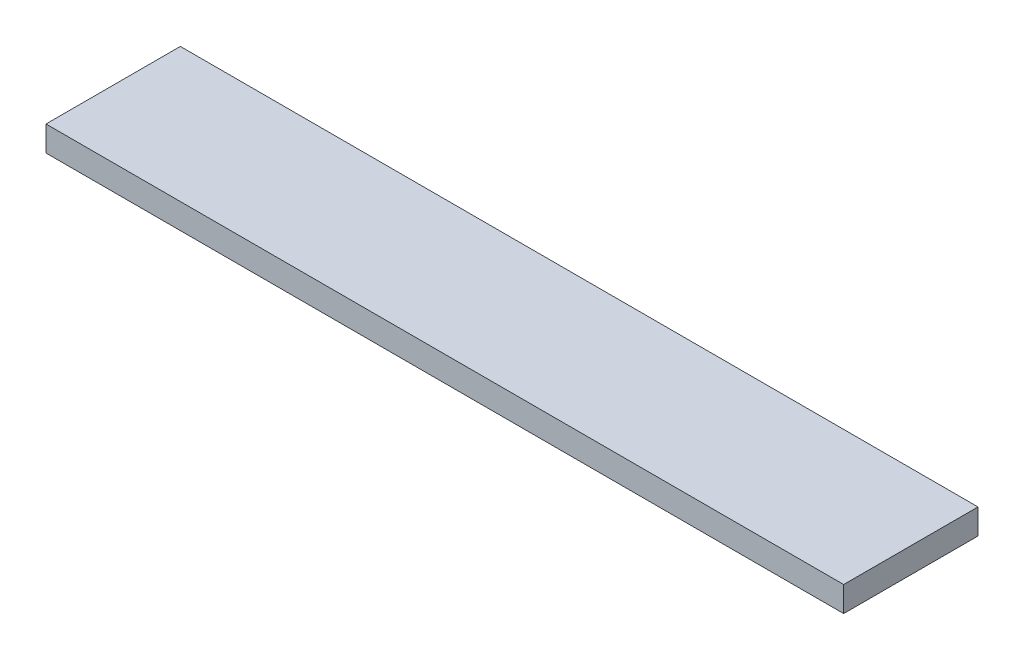
from build123d import *

# Parameters (mm, degrees)
CROQUIS1_W              = 95
CROQUIS1_H              = 16
SALIENTE_EXTRUIR1_DEPTH = 3


with BuildPart() as part:
    # Croquis1 → Saliente-Extruir1 (new body)
    with BuildSketch(Plane(origin=(0, 0, 0), x_dir=(1, 0, 0), z_dir=(0, 1, 0))):
        Rectangle(CROQUIS1_W, CROQUIS1_H)
    extrude(amount=SALIENTE_EXTRUIR1_DEPTH)


solid = part.part
